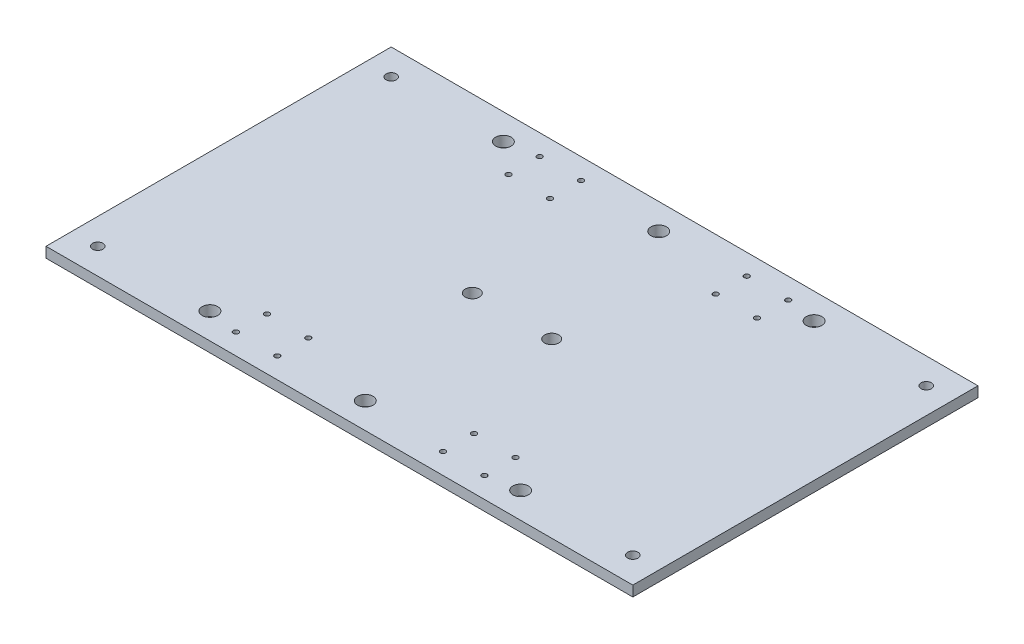
from build123d import *

# Parameters (mm, degrees)
SKETCH1_W           = 340
SKETCH1_H           = 200
SKETCH1_R           = 4.1
SKETCH1_R_2         = 1.5
SKETCH1_R_3         = 3
SKETCH1_R_4         = 4.5
BOSS_EXTRUDE1_DEPTH = 6


with BuildPart() as part:
    # Sketch1 → Boss-Extrude1 (new body)
    with BuildSketch(Plane(origin=(0, 0, 0), x_dir=(1, 0, 0), z_dir=(0, 1, 0))):
        Rectangle(SKETCH1_W, SKETCH1_H)
        with Locations((-23, 0)):
            Circle(SKETCH1_R, mode=Mode.SUBTRACT)
        with Locations((23, 0)):
            Circle(SKETCH1_R, mode=Mode.SUBTRACT)
        with Locations((72, 88)):
            Circle(SKETCH1_R_2, mode=Mode.SUBTRACT)
        with Locations((48, 88)):
            Circle(SKETCH1_R_2, mode=Mode.SUBTRACT)
        with Locations((72, 70)):
            Circle(SKETCH1_R_2, mode=Mode.SUBTRACT)
        with Locations((48, 70)):
            Circle(SKETCH1_R_2, mode=Mode.SUBTRACT)
        with Locations((-48, 70)):
            Circle(SKETCH1_R_2, mode=Mode.SUBTRACT)
        with Locations((-72, 70)):
            Circle(SKETCH1_R_2, mode=Mode.SUBTRACT)
        with Locations((-48, 88)):
            Circle(SKETCH1_R_2, mode=Mode.SUBTRACT)
        with Locations((-72, 88)):
            Circle(SKETCH1_R_2, mode=Mode.SUBTRACT)
        with Locations((-72, -88)):
            Circle(SKETCH1_R_2, mode=Mode.SUBTRACT)
        with Locations((-48, -88)):
            Circle(SKETCH1_R_2, mode=Mode.SUBTRACT)
        with Locations((-72, -70)):
            Circle(SKETCH1_R_2, mode=Mode.SUBTRACT)
        with Locations((-48, -70)):
            Circle(SKETCH1_R_2, mode=Mode.SUBTRACT)
        with Locations((48, -70)):
            Circle(SKETCH1_R_2, mode=Mode.SUBTRACT)
        with Locations((72, -70)):
            Circle(SKETCH1_R_2, mode=Mode.SUBTRACT)
        with Locations((48, -88)):
            Circle(SKETCH1_R_2, mode=Mode.SUBTRACT)
        with Locations((72, -88)):
            Circle(SKETCH1_R_2, mode=Mode.SUBTRACT)
        with Locations((155, 85)):
            Circle(SKETCH1_R_3, mode=Mode.SUBTRACT)
        with Locations((-155, 85)):
            Circle(SKETCH1_R_3, mode=Mode.SUBTRACT)
        with Locations((155, -85)):
            Circle(SKETCH1_R_3, mode=Mode.SUBTRACT)
        with Locations((-155, -85)):
            Circle(SKETCH1_R_3, mode=Mode.SUBTRACT)
        with Locations((0, 85)):
            Circle(SKETCH1_R_4, mode=Mode.SUBTRACT)
        with Locations((0, -85)):
            Circle(SKETCH1_R_4, mode=Mode.SUBTRACT)
        with Locations((90, 85)):
            Circle(SKETCH1_R_4, mode=Mode.SUBTRACT)
        with Locations((90, -85)):
            Circle(SKETCH1_R_4, mode=Mode.SUBTRACT)
        with Locations((-90, -85)):
            Circle(SKETCH1_R_4, mode=Mode.SUBTRACT)
        with Locations((-90, 85)):
            Circle(SKETCH1_R_4, mode=Mode.SUBTRACT)
    extrude(amount=BOSS_EXTRUDE1_DEPTH)


solid = part.part
